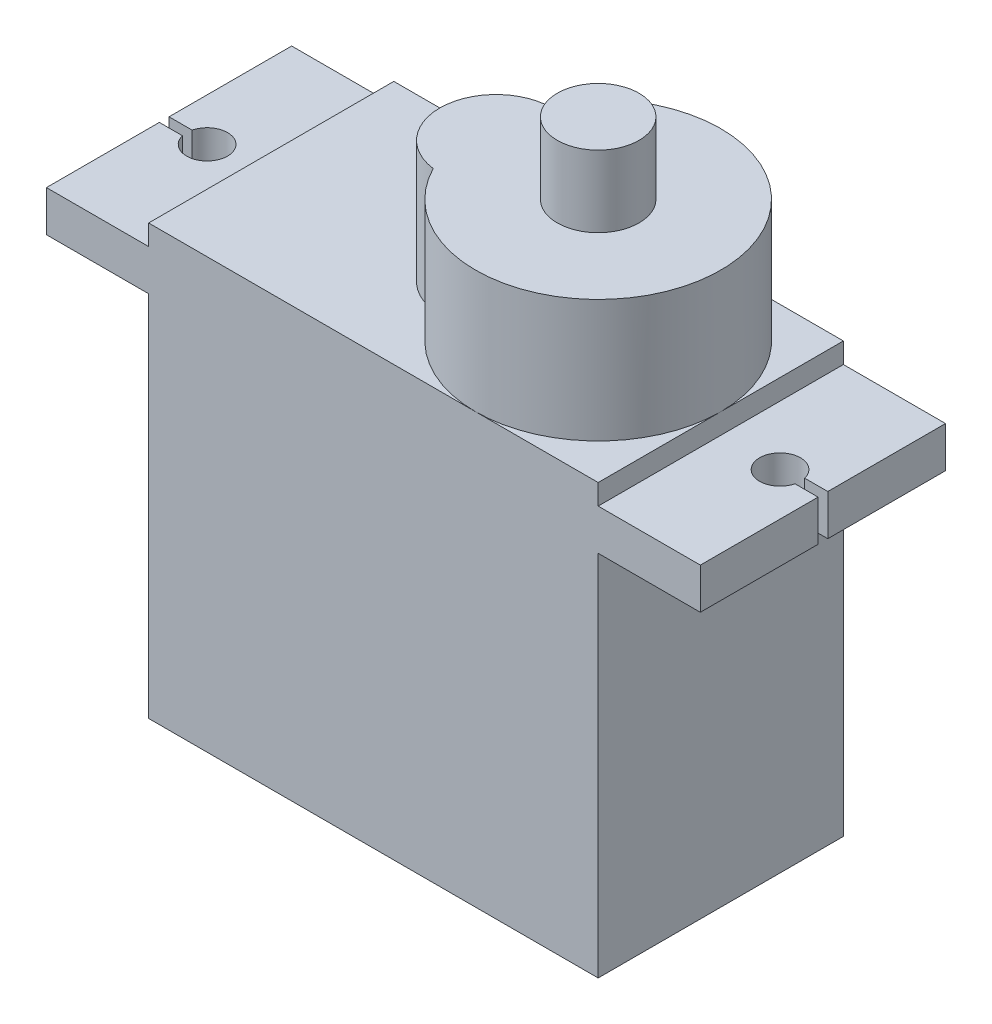
from build123d import *

# Parameters (mm, degrees)
BOSS_EXTRUDE1_DEPTH = 12
CUT_EXTRUDE1_REACH  = 22
BOSS_EXTRUDE2_DEPTH = 6
SKETCH4_R           = 2
BOSS_EXTRUDE3_DEPTH = 3.5


with BuildPart() as part:
    # Sketch1 → Boss-Extrude1 (new body)
    with BuildSketch(Plane.XY):
        Polygon((-16, 10), (-16, 8), (-11, 8), (-11, -10), (11, -10), (11, 8), (16, 8), (16, 10), (11, 10), (11, 11), (-11, 11), (-11, 10), align=None)
    extrude(amount=BOSS_EXTRUDE1_DEPTH)

    # Sketch2 → Cut-Extrude1 (cut, up to next)
    with BuildSketch(Plane(origin=(0, 10, 0), x_dir=(1, 0, 0), z_dir=(0, 1, 0)), mode=Mode.PRIVATE) as cut_extrude1_sk1:
        with BuildLine():
            Line((-16, -6), (-14.871798323, -6))
            ThreePointArc((-14.871798323, -6), (-12.900501279, -6.237869823), (-14.871798323, -6.475739646))
            Line((-14.871798323, -6.475739646), (-16, -6.475739646))
            Line((-16, -6.475739646), (-16, -6))
        make_face()
    cut_extrude1_tool1 = extrude(cut_extrude1_sk1.sketch, amount=-CUT_EXTRUDE1_REACH, mode=Mode.PRIVATE) & part.part
    add(cut_extrude1_tool1.solids().sort_by_distance((-14.122654, 10, 6.23787))[0], mode=Mode.SUBTRACT)
    # Sketch2 → Cut-Extrude1 (cut, up to next)
    with BuildSketch(Plane(origin=(0, 10, 0), x_dir=(1, 0, 0), z_dir=(0, 1, 0)), mode=Mode.PRIVATE) as cut_extrude1_sk2:
        with BuildLine():
            Line((16, -6.237869823), (14.871798323, -6.237869823))
            ThreePointArc((14.871798323, -6.237869823), (12.900501279, -6), (14.871798323, -5.762130177))
            Line((14.871798323, -5.762130177), (16, -5.762130177))
            Line((16, -5.762130177), (16, -6.237869823))
        make_face()
    cut_extrude1_tool2 = extrude(cut_extrude1_sk2.sketch, amount=-CUT_EXTRUDE1_REACH, mode=Mode.PRIVATE) & part.part
    add(cut_extrude1_tool2.solids().sort_by_distance((14.122654, 10, 6))[0], mode=Mode.SUBTRACT)

    # Sketch3 → Boss-Extrude2 (add)
    with BuildSketch(Plane(origin=(0, 11, 0), x_dir=(1, 0, 0), z_dir=(0, 1, 0))):
        with BuildLine():
            ThreePointArc((-0.34375, -8.72843104), (11, -6), (-0.34375, -3.27156896))
            ThreePointArc((-0.34375, -3.27156896), (-2.75, -6), (-0.34375, -8.72843104))
        make_face()
    extrude(amount=BOSS_EXTRUDE2_DEPTH)

    # Sketch4 → Boss-Extrude3 (add)
    with BuildSketch(Plane(origin=(0, 17, 0), x_dir=(1, 0, 0), z_dir=(0, 1, 0))):
        with Locations((5, -6)):
            Circle(SKETCH4_R)
    extrude(amount=BOSS_EXTRUDE3_DEPTH)


solid = part.part
